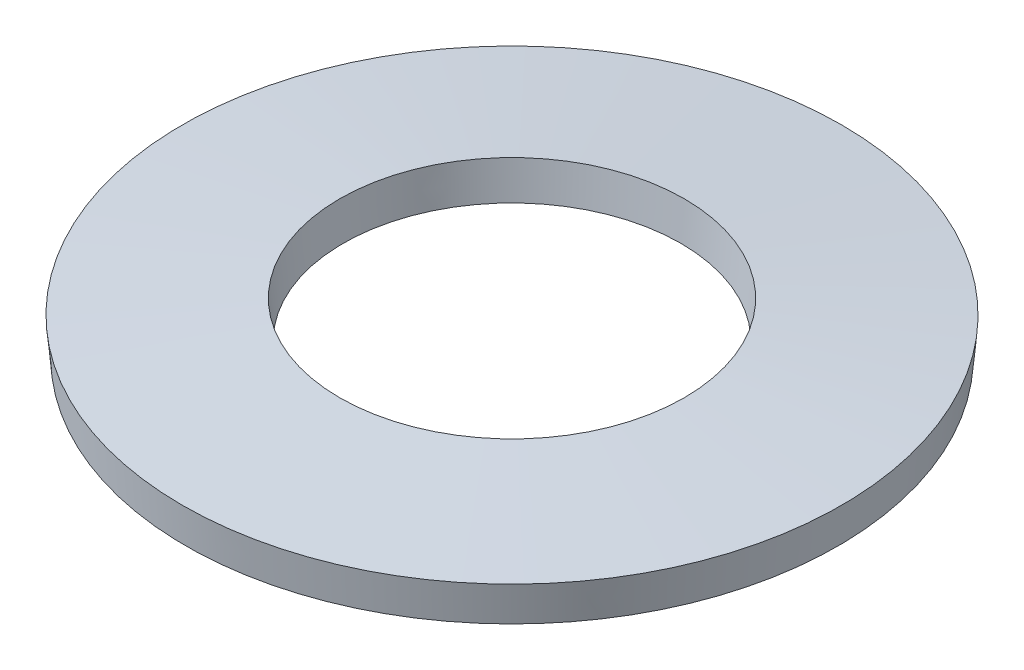
from build123d import *


with BuildPart() as part:
    # Sketch1 → Revolve1 (revolve)
    with BuildSketch(Plane.XY):
        Polygon((7.916922969, 0), (4.1, 0.353842532), (4.183077031, 1.25), (8, 0.896157468), align=None)
    revolve(axis=Axis((0, 0, 0), (0, 1, 0)))


solid = part.part
